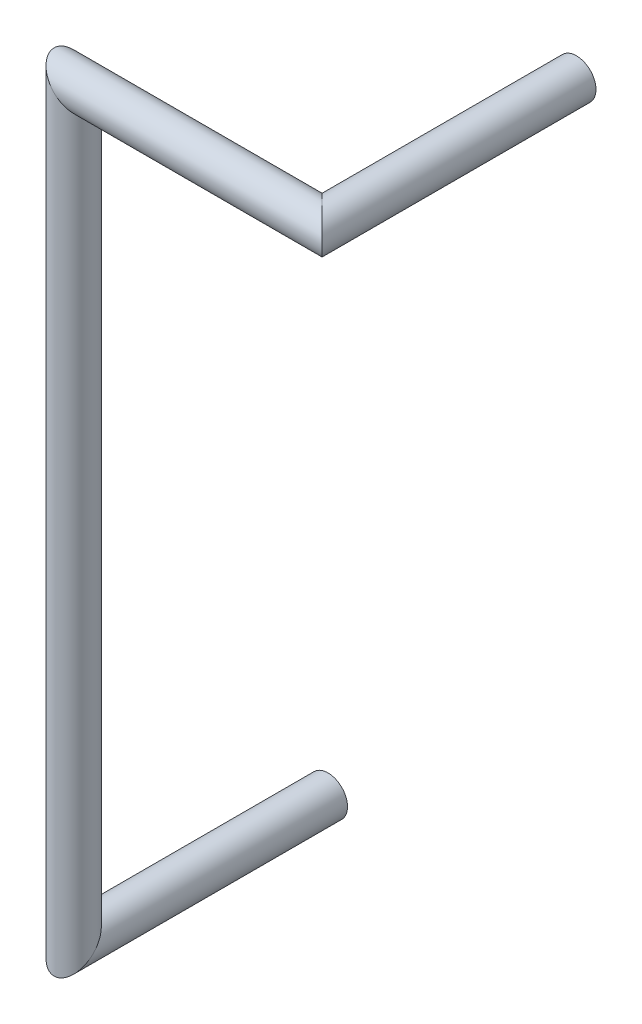
from build123d import *

# Parameters (mm, degrees)
SWEEP1_PROFILE_R = 0.2


with BuildPart() as part:
    # Sweep1: sweep along a curve in space
    with BuildLine() as sweep1_path:
        Line((0, 0, 0), (0, 0, 2.6))
        Line((0, 0, 2.6), (0, 7.62, 2.6))
        Line((0, 7.62, 2.6), (2.54, 7.62, 2.6))
        Line((2.54, 7.62, 2.6), (2.54, 7.62, 0))
    # Sweep1 profile (on start of the path) → Sweep1 (sweep)
    with BuildSketch(Plane.XY):
        Circle(SWEEP1_PROFILE_R)
    sweep(path=sweep1_path.line, transition=Transition.RIGHT)


solid = part.part
